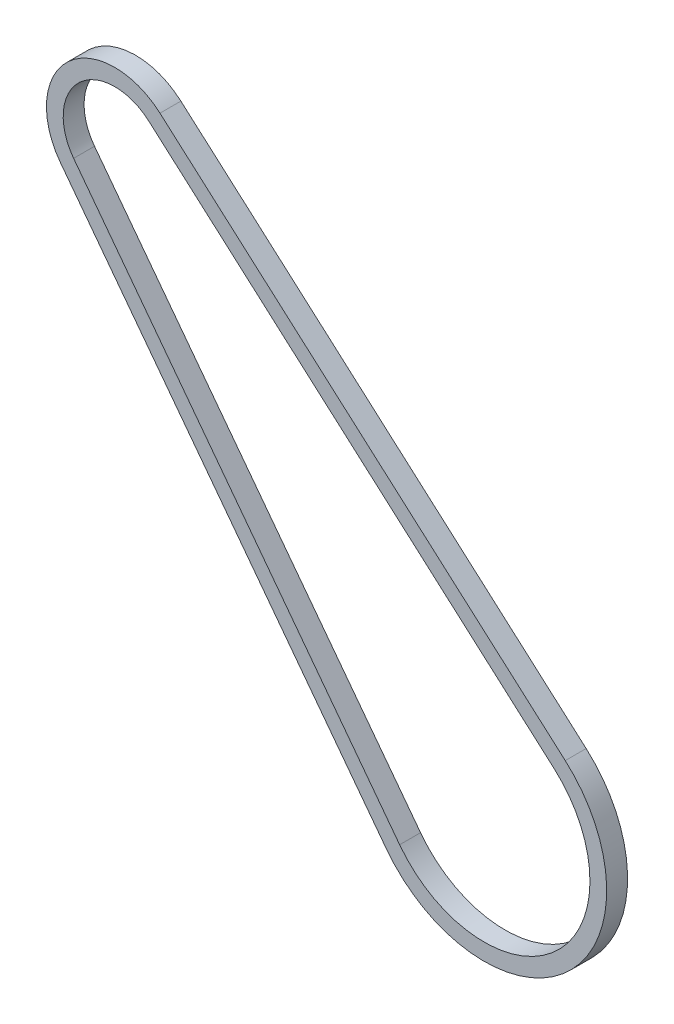
from build123d import *

# Parameters (mm, degrees)
BOSS_EXTRUDE1_DEPTH = 6.35


with BuildPart() as part:
    # Sketch1 → Boss-Extrude1 (new body)
    with BuildSketch(Plane.XY):
        with BuildLine():
            Line((-34.868423811, -17.328975991), (-133.90679935, 113.733830348))
            ThreePointArc((-133.90679935, 113.733830348), (-131.453189487, 141.460945659), (-103.619658826, 141.789116084))
            Line((-103.619658826, 141.789116084), (19.493877778, 33.027375846))
            ThreePointArc((19.493877778, 33.027375846), (20.145001377, -22.19718825), (-34.868423811, -17.328975991))
        make_face()
        with BuildLine():
            Line((-30.815453316, -14.266325151), (-129.853828855, 116.796481188))
            ThreePointArc((-129.853828855, 116.796481188), (-128.001025803, 137.734155365), (-106.982993829, 137.981967852))
            Line((-106.982993829, 137.981967852), (16.130542775, 29.220227615))
            ThreePointArc((16.130542775, 29.220227615), (16.692837693, -18.470397955), (-30.815453316, -14.266325151))
        make_face(mode=Mode.SUBTRACT)
    extrude(amount=BOSS_EXTRUDE1_DEPTH)


solid = part.part
